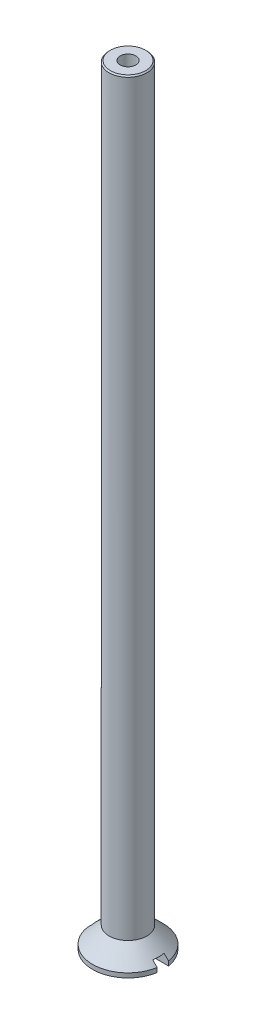
from build123d import *

# Parameters (mm, degrees)
SKETCH_1_R               = 1.5
EXTRUDE_1_DEPTH          = 61
SKETCH_3_W               = 0.9
SKETCH_3_H               = 0.7
CUT_EXTRUDE_1_DEPTH      = 3.8
CUT_EXTRUDE_1_DEPTH_BACK = 3.8
CHAMFER_1_SIZE           = 0.1
HOLE_WIZARD_M1_61_D      = 1.25
HOLE_WIZARD_M1_61_DEPTH  = 7
HOLE_WIZARD_M1_61_TIP    = 0.375537887


with BuildPart() as part:
    # Эскиз1 → Бобышка-Вытянуть1 (new body)
    with BuildSketch(Plane(origin=(0, 0, 0), x_dir=(1, 0, 0), z_dir=(0, 1, 0))):
        Circle(SKETCH_1_R)
    extrude(amount=EXTRUDE_1_DEPTH)

    # Эскиз2 → Повернуть1 (revolve)
    with BuildSketch(Plane(origin=(0, 0, 0), x_dir=(0, 0, -1), z_dir=(1, 0, 0))):
        Polygon((0, 3.15), (-2.8, 0.35), (-2.8, 0), (0, 0), align=None)
    revolve(axis=Axis((0, 0, 0), (0, 1, 0)))

    # Эскиз3 → Вырез-Вытянуть1 (cut, two sides)
    with BuildSketch(Plane(origin=(0, 0, 0), x_dir=(0, 0, -1), z_dir=(1, 0, 0))) as cut_extrude_1_sk:
        with Locations((0, 0.35)):
            Rectangle(SKETCH_3_W, SKETCH_3_H)
    extrude(amount=CUT_EXTRUDE_1_DEPTH, mode=Mode.SUBTRACT)
    extrude(cut_extrude_1_sk.sketch, amount=-CUT_EXTRUDE_1_DEPTH_BACK, mode=Mode.SUBTRACT)

    # Фаска1
    chamfer_1_edges = [part.edges().sort_by_distance(p)[0] for p in [
        (-1.5, 61, 0),
    ]]
    chamfer(chamfer_1_edges, length=CHAMFER_1_SIZE)

    # Отверстие обработанное метчиком M1,61
    with Locations(Plane(origin=(0, 61, 0), x_dir=(1, 0, 0), z_dir=(0, 1, 0))):
        with Locations((0, 0)):
            Hole(HOLE_WIZARD_M1_61_D / 2, depth=HOLE_WIZARD_M1_61_DEPTH)
            with Locations((0, 0, -(HOLE_WIZARD_M1_61_DEPTH + HOLE_WIZARD_M1_61_TIP / 2))):  # 118° drill point
                Cone(0, HOLE_WIZARD_M1_61_D / 2, HOLE_WIZARD_M1_61_TIP, mode=Mode.SUBTRACT)


solid = part.part
